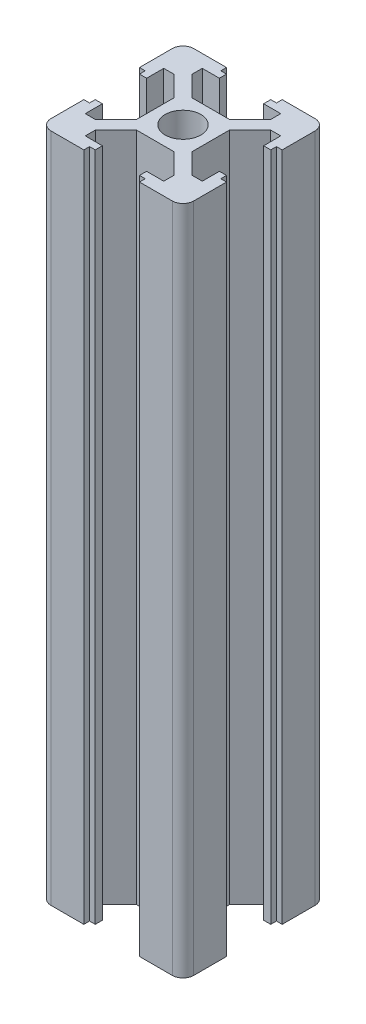
from build123d import *

# Parameters (mm, degrees)
SKETCH1_R           = 2.5
BOSS_EXTRUDE1_DEPTH = 94


with BuildPart() as part:
    # Sketch1 → Boss-Extrude1 (new body)
    with BuildSketch(Plane(origin=(0, 0, 0), x_dir=(1, 0, 0), z_dir=(0, 1, 0))):
        with BuildLine():
            Line((3.9, 10), (8.5, 10))
            ThreePointArc((8.5, 10), (9.560660172, 9.560660172), (10, 8.5))
            Line((10, 8.5), (10, 3.9))
            Line((10, 3.9), (9.2, 3.9))
            Line((9.2, 3.9), (9.2, 3.1))
            Line((9.2, 3.1), (8.2, 3.1))
            Line((8.2, 3.1), (8.2, 5.5))
            Line((8.2, 5.5), (6.77, 5.5))
            Line((6.77, 5.5), (3.9, 2.63))
            Line((3.9, 2.63), (3.9, 0))
            Line((3.9, 0), (3.9, -2.63))
            Line((3.9, -2.63), (6.77, -5.5))
            Line((6.77, -5.5), (8.2, -5.5))
            Line((8.2, -5.5), (8.2, -3.1))
            Line((8.2, -3.1), (9.2, -3.1))
            Line((9.2, -3.1), (9.2, -3.9))
            Line((9.2, -3.9), (10, -3.9))
            Line((10, -3.9), (10, -8.5))
            ThreePointArc((10, -8.5), (9.560660172, -9.560660172), (8.5, -10))
            Line((8.5, -10), (3.9, -10))
            Line((3.9, -10), (3.9, -9.2))
            Line((3.9, -9.2), (3.1, -9.2))
            Line((3.1, -9.2), (3.1, -8.2))
            Line((3.1, -8.2), (5.5, -8.2))
            Line((5.5, -8.2), (5.5, -6.77))
            Line((5.5, -6.77), (2.63, -3.9))
            Line((2.63, -3.9), (0, -3.9))
            Line((0, -3.9), (-2.63, -3.9))
            Line((-2.63, -3.9), (-5.5, -6.77))
            Line((-5.5, -6.77), (-5.5, -8.2))
            Line((-5.5, -8.2), (-3.1, -8.2))
            Line((-3.1, -8.2), (-3.1, -9.2))
            Line((-3.1, -9.2), (-3.9, -9.2))
            Line((-3.9, -9.2), (-3.9, -10))
            Line((-3.9, -10), (-8.5, -10))
            ThreePointArc((-8.5, -10), (-9.560660172, -9.560660172), (-10, -8.5))
            Line((-10, -8.5), (-10, -3.9))
            Line((-10, -3.9), (-9.2, -3.9))
            Line((-9.2, -3.9), (-9.2, -3.1))
            Line((-9.2, -3.1), (-8.2, -3.1))
            Line((-8.2, -3.1), (-8.2, -5.5))
            Line((-8.2, -5.5), (-6.77, -5.5))
            Line((-6.77, -5.5), (-3.9, -2.63))
            Line((-3.9, -2.63), (-3.9, 0))
            Line((-3.9, 0), (-3.9, 2.63))
            Line((-3.9, 2.63), (-6.77, 5.5))
            Line((-6.77, 5.5), (-8.2, 5.5))
            Line((-8.2, 5.5), (-8.2, 3.1))
            Line((-8.2, 3.1), (-9.2, 3.1))
            Line((-9.2, 3.1), (-9.2, 3.9))
            Line((-9.2, 3.9), (-10, 3.9))
            Line((-10, 3.9), (-10, 8.5))
            ThreePointArc((-10, 8.5), (-9.560660172, 9.560660172), (-8.5, 10))
            Line((-8.5, 10), (-3.9, 10))
            Line((-3.9, 10), (-3.9, 9.2))
            Line((-3.9, 9.2), (-3.1, 9.2))
            Line((-3.1, 9.2), (-3.1, 8.2))
            Line((-3.1, 8.2), (-5.5, 8.2))
            Line((-5.5, 8.2), (-5.5, 6.77))
            Line((-5.5, 6.77), (-2.63, 3.9))
            Line((-2.63, 3.9), (2.63, 3.9))
            Line((2.63, 3.9), (5.5, 6.77))
            Line((5.5, 6.77), (5.5, 8.2))
            Line((5.5, 8.2), (3.1, 8.2))
            Line((3.1, 8.2), (3.1, 9.2))
            Line((3.1, 9.2), (3.9, 9.2))
            Line((3.9, 9.2), (3.9, 10))
        make_face()
        Circle(SKETCH1_R, mode=Mode.SUBTRACT)
    extrude(amount=BOSS_EXTRUDE1_DEPTH)


solid = part.part
